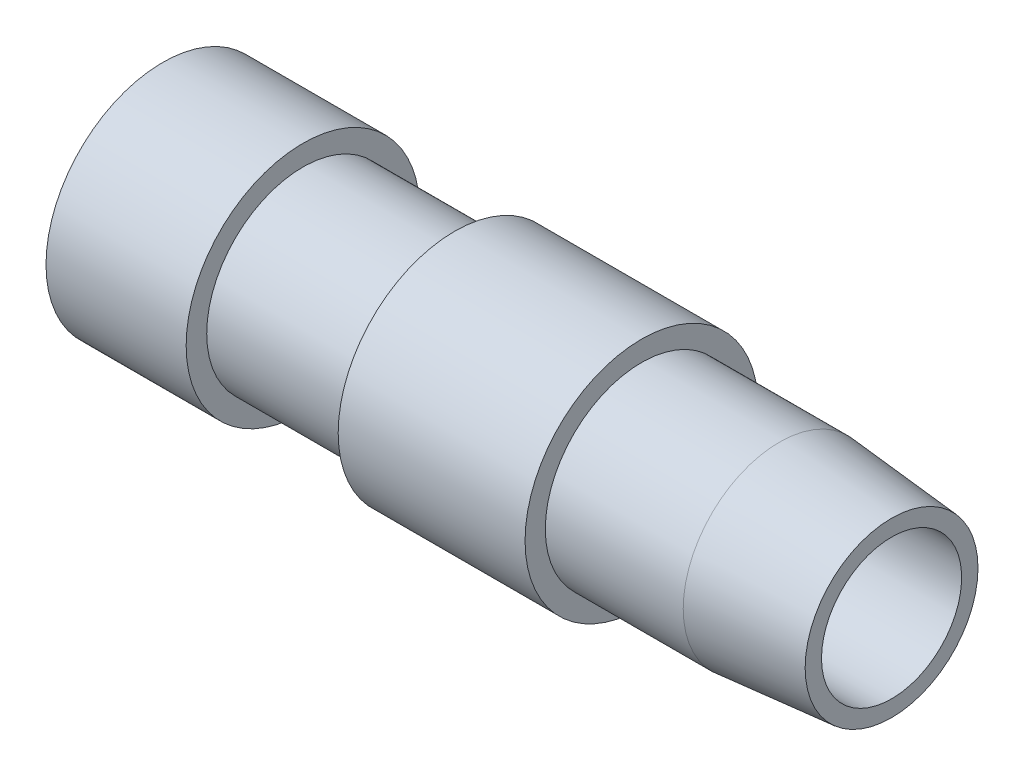
from build123d import *

# Parameters (mm, degrees)
SKETCH2_W          = 1.5875
SKETCH2_H          = 13.97
CUT_EXTRUDE1_DEPTH = 3.175


with BuildPart() as part:
    # Sketch1 → Revolve1 (revolve)
    with BuildSketch(Plane.XY):
        Polygon((0, 4.7625), (0, 7.9375), (9.525, 7.9375), (9.525, 6.5405), (19.8374, 6.5405), (19.8374, 7.91718), (32.5374, 7.91718), (32.5374, 6.5405), (41.91, 6.5405), (49.53, 5.873836384), (49.53, 4.7625), align=None)
    revolve(axis=Axis((0, 0, 0), (1, 0, 0)))

    # Sketch2 → Cut-Extrude1 (cut)
    with BuildSketch(Plane.ZY):
        Rectangle(SKETCH2_W, SKETCH2_H)
    extrude(amount=-CUT_EXTRUDE1_DEPTH, mode=Mode.SUBTRACT)


solid = part.part
